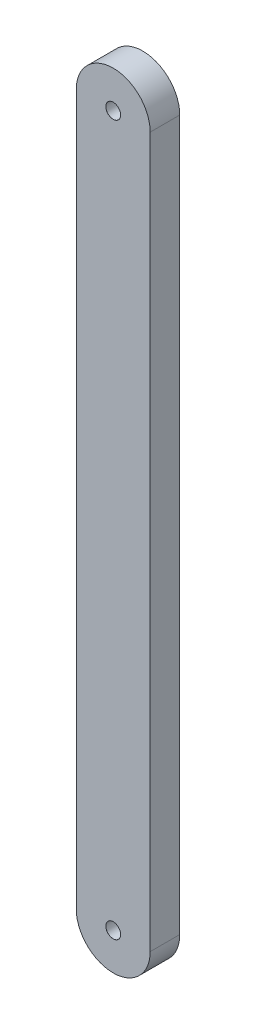
from build123d import *

# Parameters (mm, degrees)
BOSS_EXTRUDE1_DEPTH              = 20
F_10_0MM_DOWEL_HOLE1_D           = 10
F_10_0MM_DOWEL_HOLE1_CSINK_D     = 10.05
F_10_0MM_DOWEL_HOLE1_CSINK_ANGLE = 90


with BuildPart() as part:
    # Sketch2 → Boss-Extrude1 (new body)
    with BuildSketch(Plane.XY):
        with BuildLine():
            Line((-50, -240), (-50, 240))
            ThreePointArc((-50, 240), (-25, 265), (0, 240))
            Line((0, 240), (0, -240))
            ThreePointArc((0, -240), (-25, -265), (-50, -240))
        make_face()
    extrude(amount=BOSS_EXTRUDE1_DEPTH)

    # Ø10.0mm Dowel Hole1 (through all)
    with Locations(Plane.XY.offset(20)):
        with Locations((-25, 240), (-25, -240)):
            CounterSinkHole(F_10_0MM_DOWEL_HOLE1_D / 2, F_10_0MM_DOWEL_HOLE1_CSINK_D / 2, counter_sink_angle=F_10_0MM_DOWEL_HOLE1_CSINK_ANGLE)


solid = part.part
